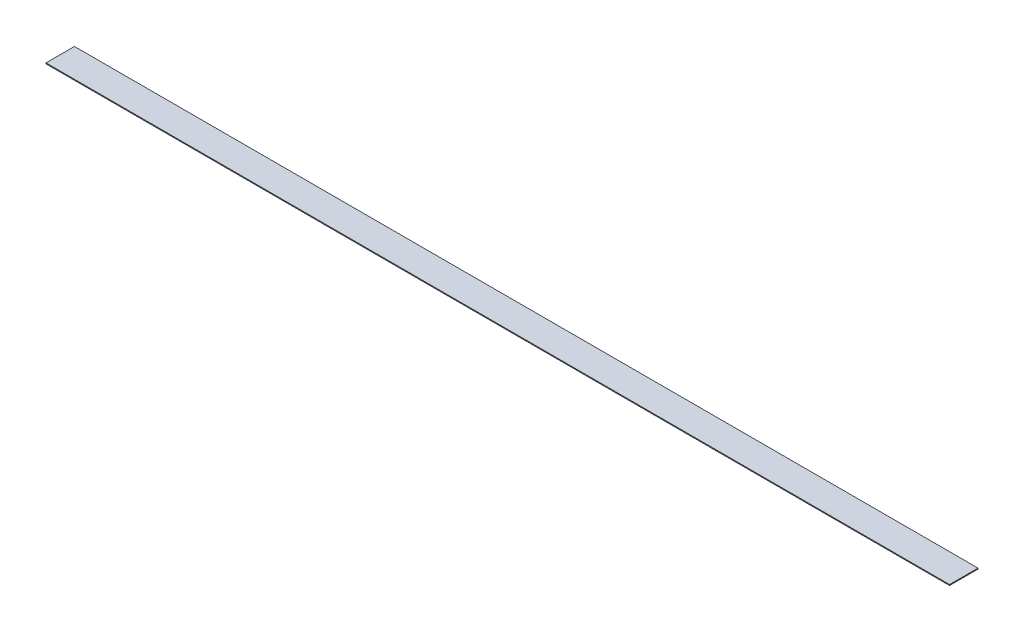
from build123d import *

# Parameters (mm, degrees)
SKETCH1_W           = 1612.9
SKETCH1_H           = 50.8
BOSS_EXTRUDE1_DEPTH = 1.5875


with BuildPart() as part:
    # Sketch1 → Boss-Extrude1 (new body)
    with BuildSketch(Plane(origin=(0, 0, 0), x_dir=(1, 0, 0), z_dir=(0, 1, 0))):
        with Locations((806.45, 25.4)):
            Rectangle(SKETCH1_W, SKETCH1_H)
    extrude(amount=BOSS_EXTRUDE1_DEPTH)


solid = part.part
